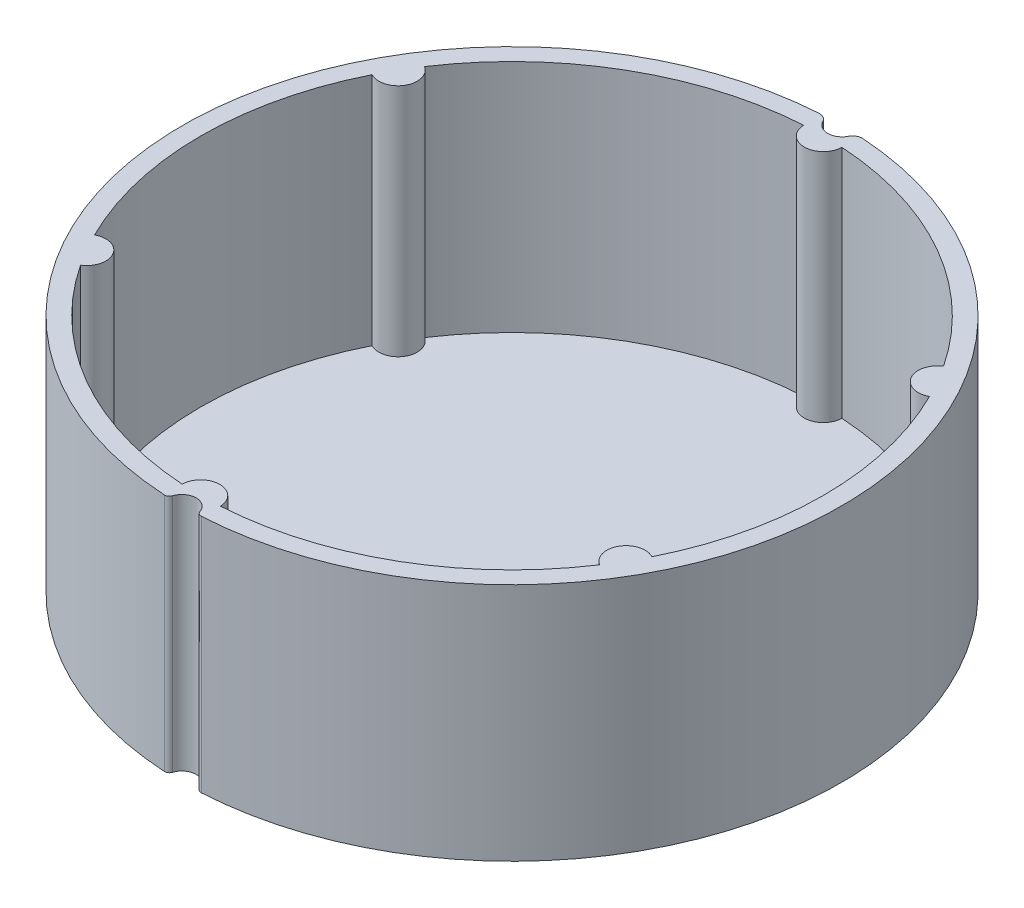
from build123d import *

# Parameters (mm, degrees)
BOSS_EXTRUDE1_DEPTH = 25
CUT_EXTRUDE2_DEPTH  = 55.66331076
BOSS_EXTRUDE2_DEPTH = 0.5


with BuildPart() as part:
    # Sketch1 → Boss-Extrude1 (new body)
    with BuildSketch(Plane(origin=(0, 0, 0), x_dir=(1, 0, 0), z_dir=(0, 1, 0))):
        with BuildLine():
            ThreePointArc((1.418185365, -33.998799682), (1.610940688, -34.258772233), (1.922534331, -34.346235045))
            ThreePointArc((1.922534331, -34.346235045), (34.399487229, -0.187825316), (2.297477624, 34.323193275))
            ThreePointArc((2.297477624, 34.323193275), (1.735753357, 34.194354817), (1.33841429, 33.776916))
            ThreePointArc((1.33841429, 33.776916), (0, 32.954150957), (-1.33841429, 33.776916))
            ThreePointArc((-1.33841429, 33.776916), (-1.735753357, 34.194354817), (-2.297477624, 34.323193275))
            ThreePointArc((-2.297477624, 34.323193275), (-34.399545597, -0.176812713), (-1.944525024, -34.344997051))
            ThreePointArc((-1.944525024, -34.344997051), (-1.632875445, -34.257733763), (-1.439953708, -33.997884682))
            ThreePointArc((-1.439953708, -33.997884682), (-0.010549885, -32.954149268), (1.418185365, -33.998799682))
        make_face()
        with BuildLine():
            Line((-2.417, 3.18717916), (0, 3.18717916))
            Line((0, 3.18717916), (2.417, 3.18717916))
            ThreePointArc((2.417, 3.18717916), (0, -4), (-2.417, 3.18717916))
        make_face(mode=Mode.SUBTRACT)
    extrude(amount=BOSS_EXTRUDE1_DEPTH)

    # Sketch2 → Cut-Extrude2 (cut, through all)
    with BuildSketch(Plane(origin=(0, 0, 0), x_dir=(1, 0, 0), z_dir=(0, 1, 0))):
        with BuildLine():
            ThreePointArc((1.99905303, 32.438461538), (0, 30.5), (-1.99905303, 32.438461538))
            ThreePointArc((-1.99905303, 32.438461538), (-16.25, 28.145825623), (-27.093005237, 17.950461477))
            ThreePointArc((-27.093005237, 17.950461477), (-26.413774815, 15.25), (-29.092058267, 14.488000062))
            ThreePointArc((-29.092058267, 14.488000062), (-32.5, 0), (-29.092058267, -14.488000062))
            ThreePointArc((-29.092058267, -14.488000062), (-26.413774815, -15.25), (-27.093005237, -17.950461477))
            ThreePointArc((-27.093005237, -17.950461477), (-16.25, -28.145825623), (-1.99905303, -32.438461538))
            ThreePointArc((-1.99905303, -32.438461538), (0, -30.5), (1.99905303, -32.438461538))
            ThreePointArc((1.99905303, -32.438461538), (16.25, -28.145825623), (27.093005237, -17.950461477))
            ThreePointArc((27.093005237, -17.950461477), (26.413774815, -15.25), (29.092058267, -14.488000062))
            ThreePointArc((29.092058267, -14.488000062), (32.5, 0), (29.092058267, 14.488000062))
            ThreePointArc((29.092058267, 14.488000062), (26.413774815, 15.25), (27.093005237, 17.950461477))
            ThreePointArc((27.093005237, 17.950461477), (16.25, 28.145825623), (1.99905303, 32.438461538))
        make_face()
    extrude(amount=CUT_EXTRUDE2_DEPTH, mode=Mode.SUBTRACT)

    # Sketch2_2 → Boss-Extrude2 (add)
    with BuildSketch(Plane(origin=(0, 0, 0), x_dir=(1, 0, 0), z_dir=(0, 1, 0))):
        with BuildLine():
            ThreePointArc((1.99905303, 32.438461538), (0, 30.5), (-1.99905303, 32.438461538))
            ThreePointArc((-1.99905303, 32.438461538), (-16.25, 28.145825623), (-27.093005237, 17.950461477))
            ThreePointArc((-27.093005237, 17.950461477), (-26.413774815, 15.25), (-29.092058267, 14.488000062))
            ThreePointArc((-29.092058267, 14.488000062), (-32.5, 0), (-29.092058267, -14.488000062))
            ThreePointArc((-29.092058267, -14.488000062), (-26.413774815, -15.25), (-27.093005237, -17.950461477))
            ThreePointArc((-27.093005237, -17.950461477), (-16.25, -28.145825623), (-1.99905303, -32.438461538))
            ThreePointArc((-1.99905303, -32.438461538), (0, -30.5), (1.99905303, -32.438461538))
            ThreePointArc((1.99905303, -32.438461538), (16.25, -28.145825623), (27.093005237, -17.950461477))
            ThreePointArc((27.093005237, -17.950461477), (26.413774815, -15.25), (29.092058267, -14.488000062))
            ThreePointArc((29.092058267, -14.488000062), (32.5, 0), (29.092058267, 14.488000062))
            ThreePointArc((29.092058267, 14.488000062), (26.413774815, 15.25), (27.093005237, 17.950461477))
            ThreePointArc((27.093005237, 17.950461477), (16.25, 28.145825623), (1.99905303, 32.438461538))
        make_face()
    extrude(amount=BOSS_EXTRUDE2_DEPTH)


solid = part.part
